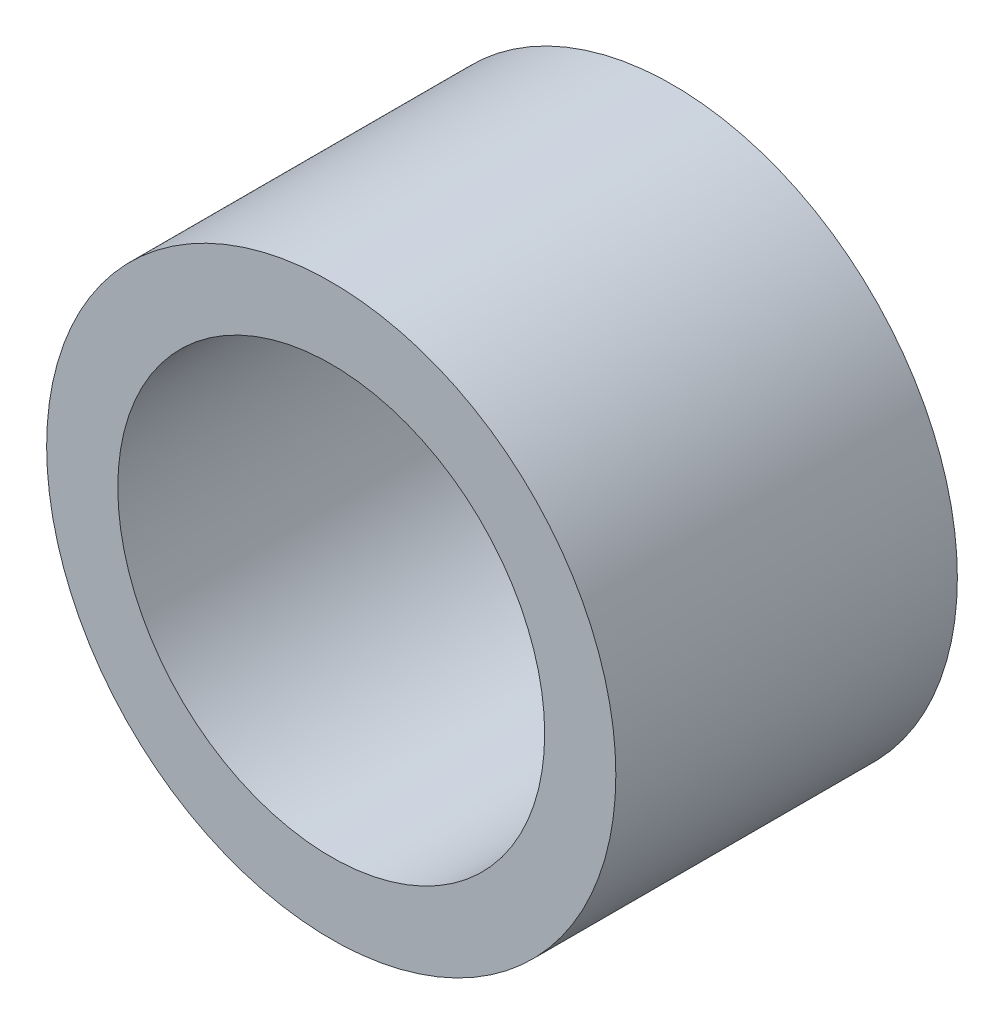
from build123d import *

# Parameters (mm, degrees)
SKETCH2_R           = 4.233333333
SKETCH2_R_2         = 3.175
BOSS_EXTRUDE1_DEPTH = 5.08


with BuildPart() as part:
    # Sketch2 → Boss-Extrude1 (new body)
    with BuildSketch(Plane.XY):
        Circle(SKETCH2_R)
        Circle(SKETCH2_R_2, mode=Mode.SUBTRACT)
    extrude(amount=BOSS_EXTRUDE1_DEPTH)


solid = part.part
